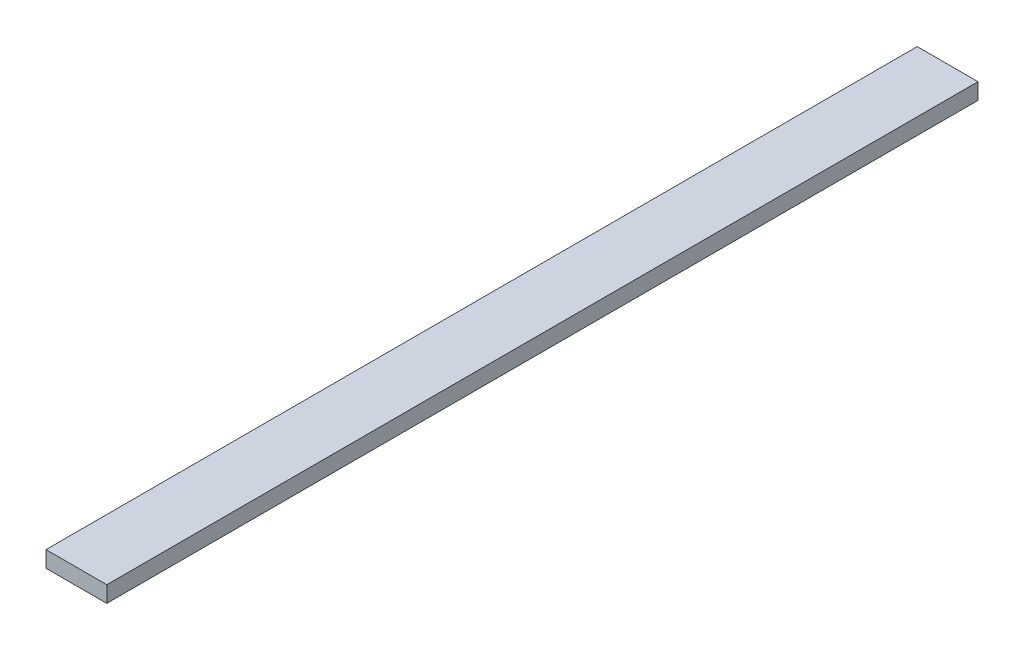
from build123d import *

# Parameters (mm, degrees)
SKETCH_1_W      = 30
SKETCH_1_H      = 8
EXTRUDE_1_DEPTH = 430


with BuildPart() as part:
    # 草图1 → 凸台-拉伸1 (new body)
    with BuildSketch(Plane.XY):
        Rectangle(SKETCH_1_W, SKETCH_1_H)
    extrude(amount=EXTRUDE_1_DEPTH)


solid = part.part
